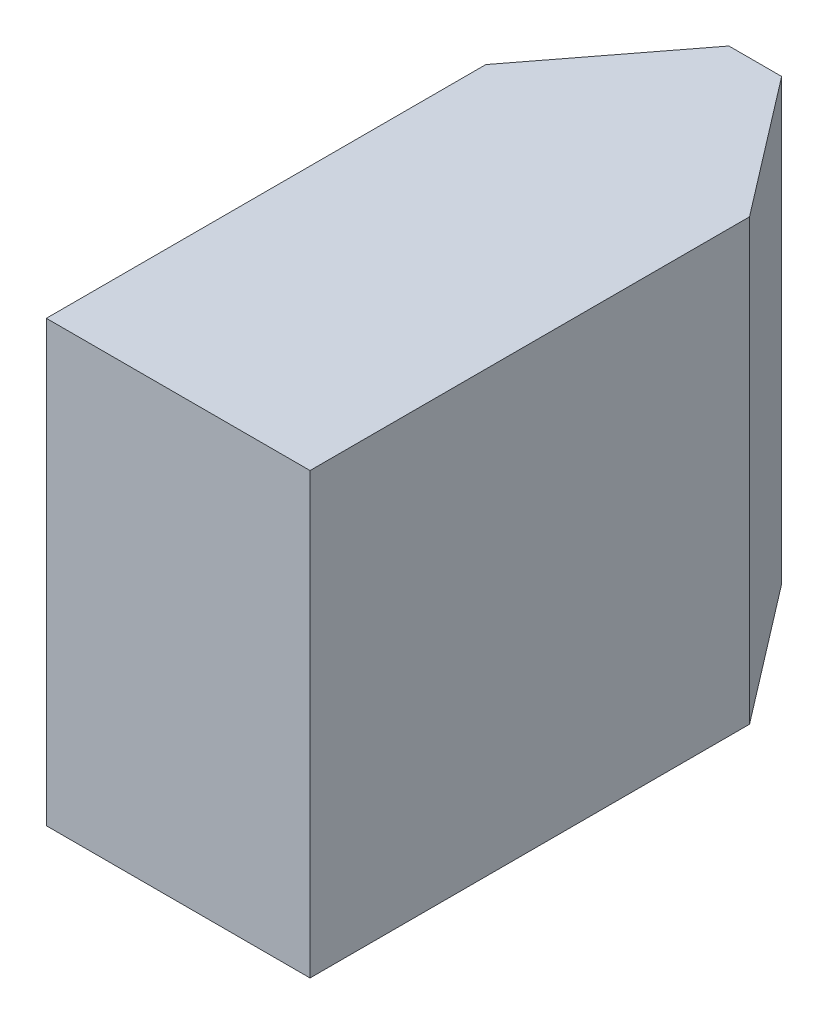
from build123d import *

# Parameters (mm, degrees)
EXTRUDE_1_DEPTH = 50


with BuildPart() as part:
    # Эскиз1 → Бобышка-Вытянуть1 (new body)
    with BuildSketch(Plane(origin=(0, 0, 0), x_dir=(1, 0, 0), z_dir=(0, 1, 0))):
        Polygon((-15, 50), (-3, 65.6560148), (3, 65.6560148), (15, 50), (15, 0), (-15, 0), align=None)
    extrude(amount=EXTRUDE_1_DEPTH)


solid = part.part
